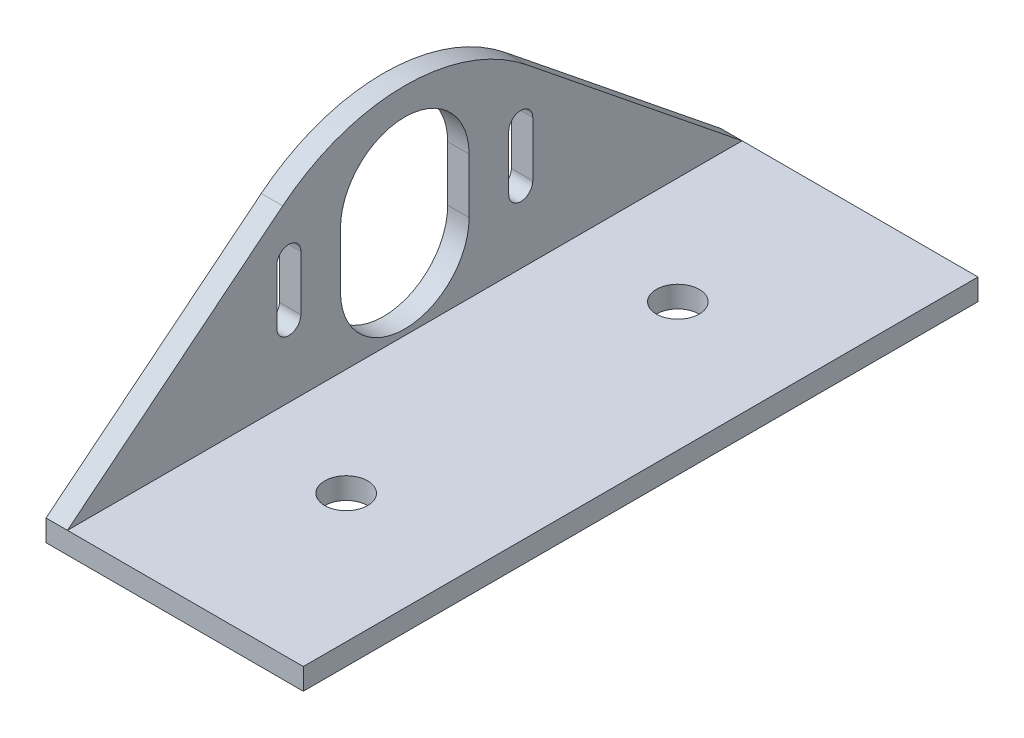
from build123d import *

# Parameters (mm, degrees)
SKETCH1_W           = 133.35
SKETCH1_H           = 50.8
BOSS_EXTRUDE1_DEPTH = 3.175
SKETCH4_W           = 76.2
SKETCH4_H           = 3.175
BOSS_EXTRUDE2_DEPTH = 147.32
SKETCH3_R           = 3.175
CUT_EXTRUDE2_DEPTH  = 4.175
SKETCH5_W           = 133.35
SKETCH5_H           = 88.9
CUT_EXTRUDE3_DEPTH  = 4.175
SKETCH7_W           = 22.225
SKETCH7_H           = 109.22
CUT_EXTRUDE4_DEPTH  = 4.175
SKETCH8_OUTSIDE_W   = 80.349
SKETCH8_OUTSIDE_H   = 135.594
SKETCH8_OUTSIDE_W_2 = 47.625
SKETCH8_OUTSIDE_H_2 = 99.906666667
CUT_EXTRUDE5_DEPTH  = 4.175
BOSS_EXTRUDE4_DEPTH = 3.175
SKETCH10_W          = 12.7
SKETCH10_H          = 99.906666667
CUT_EXTRUDE6_DEPTH  = 4.175
CUT_EXTRUDE7_DEPTH  = 39.1


with BuildPart() as part:
    # Sketch1 → Boss-Extrude1 (new body)
    with BuildSketch(Plane(origin=(0, 0, 0), x_dir=(1, 0, 0), z_dir=(0, 1, 0))):
        Rectangle(SKETCH1_W, SKETCH1_H)
    extrude(amount=BOSS_EXTRUDE1_DEPTH)

    # Sketch4 → Boss-Extrude2 (add)
    with BuildSketch(Plane.XY.offset(25.4)):
        with Locations((0, 1.5875)):
            Rectangle(SKETCH4_W, SKETCH4_H)
    extrude(amount=BOSS_EXTRUDE2_DEPTH)

    # Sketch3 → Cut-Extrude2 (cut, through all)
    with BuildSketch(Plane(origin=(0, 3.175, 0), x_dir=(1, 0, 0), z_dir=(0, 1, 0))):
        Circle(SKETCH3_R)
        with Locations((0, -49.106666667)):
            Circle(SKETCH3_R)
        with Locations((0, -98.213333333)):
            Circle(SKETCH3_R)
        with Locations((0, -147.32)):
            Circle(SKETCH3_R)
    extrude(amount=-CUT_EXTRUDE2_DEPTH, mode=Mode.SUBTRACT)

    # Sketch5 → Cut-Extrude3 (cut, through all)
    with BuildSketch(Plane(origin=(0, 3.175, 0), x_dir=(1, 0, 0), z_dir=(0, 1, 0))):
        with Locations((0, -19.05)):
            Rectangle(SKETCH5_W, SKETCH5_H)
    extrude(amount=-CUT_EXTRUDE3_DEPTH, mode=Mode.SUBTRACT)

    # Sketch7 → Cut-Extrude4 (cut, through all)
    with BuildSketch(Plane(origin=(0, 3.175, 0), x_dir=(1, 0, 0), z_dir=(0, 1, 0))):
        with Locations((-26.9875, -118.11)):
            Rectangle(SKETCH7_W, SKETCH7_H)
    extrude(amount=-CUT_EXTRUDE4_DEPTH, mode=Mode.SUBTRACT)

    # Sketch8 outside → Cut-Extrude5 (cut, through all)
    with BuildSketch(Plane(origin=(0, 3.175, 0), x_dir=(1, 0, 0), z_dir=(0, 1, 0))):
        with Locations((11.1125, -118.11)):
            Rectangle(SKETCH8_OUTSIDE_W, SKETCH8_OUTSIDE_H)
        with Locations((7.9375, -122.766666667)):
            Rectangle(SKETCH8_OUTSIDE_W_2, SKETCH8_OUTSIDE_H_2, mode=Mode.SUBTRACT)
    extrude(amount=-CUT_EXTRUDE5_DEPTH, mode=Mode.SUBTRACT)

    # Sketch9 → Boss-Extrude4 (add)
    with BuildSketch(Plane.ZY.offset(15.875)):
        with BuildLine():
            Line((172.72, 3.175), (140.847432308, 28.849821314))
            ThreePointArc((140.847432308, 28.849821314), (122.766666667, 35.226473065), (104.685901025, 28.849821314))
            Line((104.685901025, 28.849821314), (72.813333333, 3.175))
            Line((72.813333333, 3.175), (72.813333333, 0))
            Line((72.813333333, 0), (172.72, 0))
            Line((172.72, 0), (172.72, 3.175))
        make_face()
    extrude(amount=BOSS_EXTRUDE4_DEPTH)

    # Sketch10 → Cut-Extrude6 (cut, through all)
    with BuildSketch(Plane(origin=(0, 3.175, 0), x_dir=(1, 0, 0), z_dir=(0, 1, 0))):
        with Locations((25.4, -122.766666667)):
            Rectangle(SKETCH10_W, SKETCH10_H)
    extrude(amount=-CUT_EXTRUDE6_DEPTH, mode=Mode.SUBTRACT)

    # Sketch11 → Cut-Extrude7 (cut, through all)
    with BuildSketch(Plane.ZY.offset(19.05)):
        with BuildLine():
            Line((132.291666667, 21.680516849), (132.291666667, 13.545956216))
            ThreePointArc((132.291666667, 13.545956216), (122.766666667, 4.020956216), (113.241666667, 13.545956216))
            Line((113.241666667, 13.545956216), (113.241666667, 21.680516849))
            ThreePointArc((113.241666667, 21.680516849), (122.766666667, 31.205516849), (132.291666667, 21.680516849))
        make_face()
        with BuildLine():
            Line((141.71638956, 21.680516849), (141.71638956, 13.545956216))
            ThreePointArc((141.71638956, 13.545956216), (139.93838956, 11.767956216), (138.16038956, 13.545956216))
            Line((138.16038956, 13.545956216), (138.16038956, 21.680516849))
            ThreePointArc((138.16038956, 21.680516849), (139.93838956, 23.458516849), (141.71638956, 21.680516849))
        make_face()
        with BuildLine():
            Line((107.372943773, 21.680516849), (107.372943773, 13.545956216))
            ThreePointArc((107.372943773, 13.545956216), (105.594943773, 11.767956216), (103.816943773, 13.545956216))
            Line((103.816943773, 13.545956216), (103.816943773, 21.680516849))
            ThreePointArc((103.816943773, 21.680516849), (105.594943773, 23.458516849), (107.372943773, 21.680516849))
        make_face()
    extrude(amount=-CUT_EXTRUDE7_DEPTH, mode=Mode.SUBTRACT)


solid = part.part
